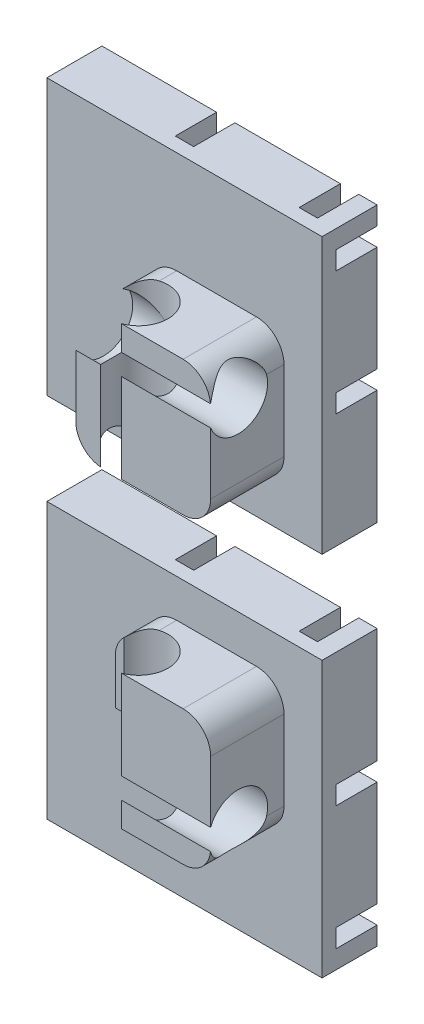
from build123d import *

# Parameters (mm, degrees)
SKETCH1_W           = 30
SKETCH1_H           = 30
COVER_DEPTH         = 6
SKETCH2_W           = 14.7
SKETCH2_H           = 14.7
PLUG_DEPTH          = 8
SKETCH3_W           = 30
SKETCH3_H           = 2
CUT_EXTRUDE1_DEPTH  = 4.5
FILLET1_R           = 3
SKETCH7_W           = 2
SKETCH7_H           = 30
CUT_EXTRUDE5_DEPTH  = 4.5
CUT_EXTRUDE8_REACH  = 46.677
SKETCH10_R          = 3.21
CUT_EXTRUDE6_REACH  = 46.677
SKETCH8_R           = 3.21
SKETCH11_R          = 0.4
CUT_EXTRUDE9_DEPTH  = 0.3
SKETCH12_W          = 5.786854718
SKETCH12_H          = 13.066730134
CUT_EXTRUDE10_DEPTH = 1.35


with BuildPart() as part:
    # Sketch1 → cover (new body)
    with BuildSketch(Plane.XY):
        with Locations((15, 15)):
            Rectangle(SKETCH1_W, SKETCH1_H)
    extrude(amount=COVER_DEPTH)

    # Sketch2 → plug (add)
    with BuildSketch(Plane.XY.offset(6)):
        with Locations((18.5, 18.5)):
            Rectangle(SKETCH2_W, SKETCH2_H)
    extrude(amount=PLUG_DEPTH)

    # Sketch3 → Cut-Extrude1 (cut)
    with BuildSketch(Plane(origin=(0, 0, 0), x_dir=(-1, 0, 0), z_dir=(0, 0, -1))):
        with Locations((-15, 3)):
            Rectangle(SKETCH3_W, SKETCH3_H)
        with Locations((-15, 16.5)):
            Rectangle(SKETCH3_W, SKETCH3_H)
    extrude(amount=-CUT_EXTRUDE1_DEPTH, mode=Mode.SUBTRACT)

    # Fillet1
    fillet1_edges = [part.edges().sort_by_distance(p)[0] for p in [
        (11.15, 25.85, 10),
        (11.15, 11.15, 10),
        (25.85, 11.15, 10),
        (25.85, 25.85, 10),
    ]]
    fillet(fillet1_edges, radius=FILLET1_R)

    # Sketch7 → Cut-Extrude5 (cut)
    with BuildSketch(Plane(origin=(0, 0, 0), x_dir=(-1, 0, 0), z_dir=(0, 0, -1))):
        with Locations((-27, 15)):
            Rectangle(SKETCH7_W, SKETCH7_H)
        with Locations((-13.5, 15)):
            Rectangle(SKETCH7_W, SKETCH7_H)
    extrude(amount=-CUT_EXTRUDE5_DEPTH, mode=Mode.SUBTRACT)

    # Cut-Extrude8: up to this face of the body (flat: up to its plane)
    cut_extrude8_end = Plane(part.part.faces().sort_by_distance((18.5, 25.85, 10))[0])
    # Sketch10 → Cut-Extrude8 (cut, up to the picked face)
    with BuildSketch(Plane.XZ, mode=Mode.PRIVATE) as cut_extrude8_sk1:
        with Locations((15, 11)):
            Circle(SKETCH10_R)
    cut_extrude8_tool1 = split(extrude(cut_extrude8_sk1.sketch, amount=-CUT_EXTRUDE8_REACH, mode=Mode.PRIVATE), bisect_by=cut_extrude8_end, keep=Keep.BOTH, mode=Mode.PRIVATE)
    add(cut_extrude8_tool1.solids().sort_by(Axis((15, 0, 11), (0, 1, 0)))[0], mode=Mode.SUBTRACT)

    # Cut-Extrude6: up to this face of the body (flat: up to its plane)
    cut_extrude6_end = Plane(part.part.faces().sort_by_distance((11.15, 18.5, 10))[0])
    # Sketch8 → Cut-Extrude6 (cut, up to the picked face)
    with BuildSketch(Plane(origin=(30, 0, 0), x_dir=(0, 0, -1), z_dir=(1, 0, 0)), mode=Mode.PRIVATE) as cut_extrude6_sk1:
        with Locations((-11, 15)):
            Circle(SKETCH8_R)
    cut_extrude6_tool1 = split(extrude(cut_extrude6_sk1.sketch, amount=-CUT_EXTRUDE6_REACH, mode=Mode.PRIVATE), bisect_by=cut_extrude6_end, keep=Keep.BOTH, mode=Mode.PRIVATE)
    add(cut_extrude6_tool1.solids().sort_by(Axis((30, 15, 11), (-1, 0, 0)))[0], mode=Mode.SUBTRACT)


with BuildPart() as cut_extrude6_piece_1:
    # of the separate pieces the step leaves, piece 1, a body of its own (cut_extrude6_pieces)
    add(part.part.solids().sort_by_distance((11.15, 14.15, 6))[0])

    # Sketch11 → Cut-Extrude9 (cut)
    with BuildSketch(Plane(origin=(0, 0, 0), x_dir=(-1, 0, 0), z_dir=(0, 0, -1))):
        with Locations((-1.023534147, 0.957517398)):
            Circle(SKETCH11_R)
    extrude(amount=-CUT_EXTRUDE9_DEPTH, mode=Mode.SUBTRACT)


with BuildPart() as cut_extrude6_piece_2:
    # of the separate pieces the step leaves, piece 2, a body of its own (cut_extrude6_pieces)
    add(part.part.solids().sort_by_distance((11.164241744, 13.858028021, 14))[0])


with BuildPart() as body_2:
    # Mirror3: mirrored copy
    add(cut_extrude6_piece_1.part.mirror(Plane.ZX.offset(35)))


with BuildPart() as cut_extrude6_piece_1_1:
    add(cut_extrude6_piece_1.part)

    # Sketch12 → Cut-Extrude10 (cut)
    with BuildSketch(Plane.ZY.offset(-11.15)):
        with Locations((12.582845038, 21.167796202)):
            Rectangle(SKETCH12_W, SKETCH12_H)
    extrude(amount=-CUT_EXTRUDE10_DEPTH, mode=Mode.SUBTRACT)


with BuildPart() as cut_extrude10_kept_piece:
    # of the separate pieces the step leaves, the one the design keeps (cut_extrude10_pieces_kept)
    add(cut_extrude6_piece_1_1.part.solids().sort_by_distance((11.15, 14.15, 6))[0])


solid = Compound([body_2.part, cut_extrude10_kept_piece.part])
